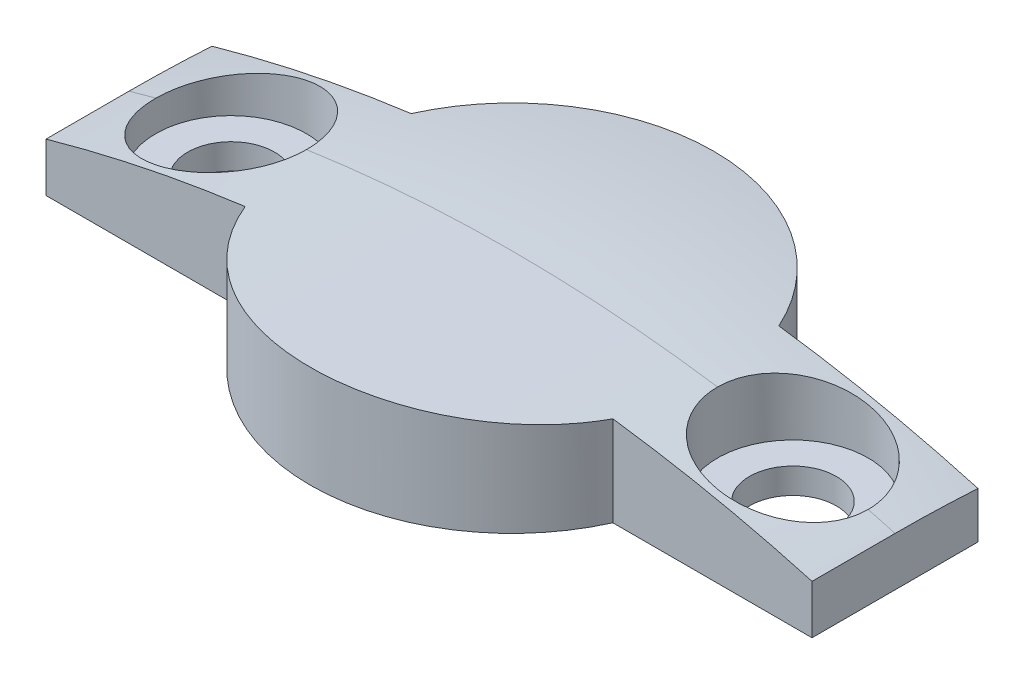
from build123d import *

# Parameters (mm, degrees)
SALIENTE_EXTRUIR1_DEPTH = 4
CROQUIS2_R              = 1.7
CORTAR_EXTRUIR1_DEPTH   = 4
CROQUIS3_R              = 2.95
CORTAR_EXTRUIR2_DEPTH   = 3


with BuildPart() as part:
    # Croquis1 → Saliente-Extruir1 (new body)
    with BuildSketch(Plane(origin=(0, 0, 0), x_dir=(1, 0, 0), z_dir=(0, 1, 0))):
        with BuildLine():
            Line((-7.200520814, 3.25), (-15, 3.25))
            Line((-15, 3.25), (-15, -3.25))
            Line((-15, -3.25), (-7.200520814, -3.25))
            ThreePointArc((-7.200520814, -3.25), (0, -7.9), (7.200520814, -3.25))
            Line((7.200520814, -3.25), (15, -3.25))
            Line((15, -3.25), (15, 3.25))
            Line((15, 3.25), (7.200520814, 3.25))
            ThreePointArc((7.200520814, 3.25), (0, 7.9), (-7.200520814, 3.25))
        make_face()
    extrude(amount=SALIENTE_EXTRUIR1_DEPTH)

    # Croquis2 → Cortar-Extruir1 (cut)
    with BuildSketch(Plane(origin=(0, 4, 0), x_dir=(1, 0, 0), z_dir=(0, 1, 0))):
        with Locations((-11, 0)):
            Circle(CROQUIS2_R)
        with Locations((11, 0)):
            Circle(CROQUIS2_R)
    extrude(amount=-CORTAR_EXTRUIR1_DEPTH, mode=Mode.SUBTRACT)

    # Croquis3 → Cortar-Extruir2 (cut)
    with BuildSketch(Plane(origin=(0, 4, 0), x_dir=(1, 0, 0), z_dir=(0, 1, 0))):
        with Locations((-11, 0)):
            Circle(CROQUIS3_R)
        with Locations((11, 0)):
            Circle(CROQUIS3_R)
    extrude(amount=-CORTAR_EXTRUIR2_DEPTH, mode=Mode.SUBTRACT)

    # Croquis4 → Cortar-Revolución1 (revolve, cut)
    with BuildSketch(Plane(origin=(0, 0, 0), x_dir=(0, 0, -1), z_dir=(1, 0, 0))):
        with BuildLine():
            Line((0, 4), (-10, 4))
            Line((-10, 4), (-10, 7))
            Line((-10, 7), (10, 7))
            Line((10, 7), (10, 3.083269132))
            ThreePointArc((10, 3.083269132), (5.02096593, 3.770337785), (0, 4))
        make_face()
    revolve(axis=Axis((0, -51, 21.725989645), (0, 0, -1)), mode=Mode.SUBTRACT)


solid = part.part
